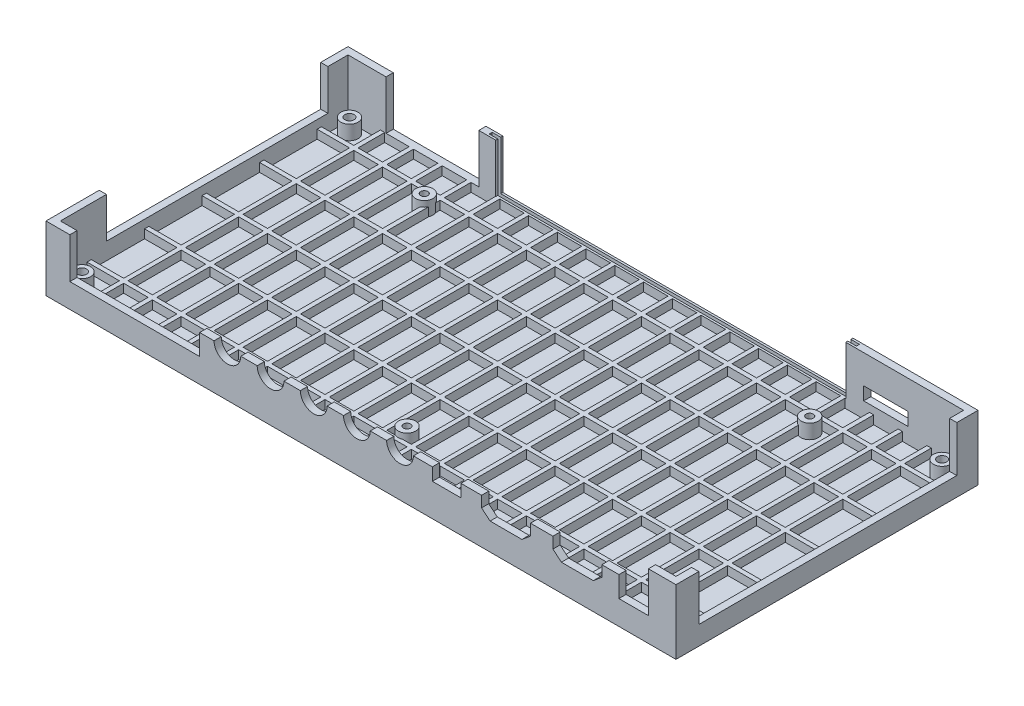
from build123d import *

# Parameters (mm, degrees)
SKETCH1_W                                    = 219
SKETCH1_H                                    = 105
SKETCH1_W_2                                  = 214
SKETCH1_H_2                                  = 100
BOSS_EXTRUDE1_DEPTH                          = 20
SKETCH1_3_W                                  = 219
SKETCH1_3_H                                  = 105
BOSS_EXTRUDE2_DEPTH                          = 2.5
SKETCH3_W                                    = 201.121255631
SKETCH3_H                                    = 14.10529534
CUT_EXTRUDE1_DEPTH                           = 10
SKETCH4_W                                    = 89.704948929
SKETCH4_H                                    = 15.953853078
CUT_EXTRUDE2_DEPTH                           = 10
BOSS_EXTRUDE3_DEPTH                          = 2.5
SKETCH6_W                                    = 92
SKETCH6_H                                    = 17
CUT_EXTRUDE3_DEPTH                           = 10
SKETCH7_W                                    = 77
SKETCH7_H                                    = 14.1
CUT_EXTRUDE4_DEPTH                           = 10
SKETCH8_W                                    = 48.543496453
SKETCH8_H                                    = 17
CUT_EXTRUDE5_DEPTH                           = 4
SKETCH9_W                                    = 15.379744564
SKETCH9_H                                    = 4.533254645
CUT_EXTRUDE6_DEPTH                           = 4
SKETCH10_W                                   = 8.868629792
SKETCH10_H                                   = 12.563679554
CUT_EXTRUDE7_DEPTH                           = 4
BOSS_EXTRUDE4_DEPTH                          = 5
CBORE_FOR_M3_HEX_HEAD_CAP_SCREW1_D           = 3.2
CBORE_FOR_M3_HEX_HEAD_CAP_SCREW1_DEPTH       = 10.1
CBORE_FOR_M3_HEX_HEAD_CAP_SCREW1_CBORE_D     = 5.5
CBORE_FOR_M3_HEX_HEAD_CAP_SCREW1_CBORE_DEPTH = 2.5
CBORE_FOR_M3_HEX_HEAD_CAP_SCREW1_TIP         = 0.96137699
SKETCH17_R                                   = 3
BOSS_EXTRUDE5_DEPTH                          = 5
M3_TAPPED_HOLE1_D                            = 2.5
M3_TAPPED_HOLE1_DEPTH                        = 5
M3_TAPPED_HOLE1_TIP                          = 0.751075774
BOSS_EXTRUDE6_DEPTH                          = 2.5
SKETCH23_W                                   = 20.036006658
SKETCH23_H                                   = 17
CUT_EXTRUDE8_DEPTH                           = 10
SKETCH24_W                                   = 5.878138763
SKETCH24_H                                   = 17
BOSS_EXTRUDE7_DEPTH                          = 2.5
SKETCH25_W                                   = 127.698647885
SKETCH25_H                                   = 1.05
CUT_EXTRUDE9_DEPTH                           = 19
SKETCH26_W                                   = 1.5
SKETCH26_H                                   = 100
BOSS_EXTRUDE8_DEPTH                          = 3
SKETCH27_W                                   = 214
SKETCH27_H                                   = 1.5
BOSS_EXTRUDE9_DEPTH                          = 3


with BuildPart() as part:
    # Sketch1 → Boss-Extrude1 (new body)
    with BuildSketch(Plane(origin=(0, 0, 0), x_dir=(1, 0, 0), z_dir=(0, 1, 0))):
        Rectangle(SKETCH1_W, SKETCH1_H)
        Rectangle(SKETCH1_W_2, SKETCH1_H_2, mode=Mode.SUBTRACT)
    extrude(amount=BOSS_EXTRUDE1_DEPTH)

    # Sketch1_3 → Boss-Extrude2 (add)
    with BuildSketch(Plane(origin=(0, 0, 0), x_dir=(1, 0, 0), z_dir=(0, 1, 0))):
        Rectangle(SKETCH1_3_W, SKETCH1_3_H)
    extrude(amount=-BOSS_EXTRUDE2_DEPTH)

    # Sketch3 → Cut-Extrude1 (cut)
    with BuildSketch(Plane.XY.offset(52.5)):
        with Locations((-0.640205513, 12.94735233)):
            Rectangle(SKETCH3_W, SKETCH3_H)
    extrude(amount=-CUT_EXTRUDE1_DEPTH, mode=Mode.SUBTRACT)

    # Sketch4 → Cut-Extrude2 (cut)
    with BuildSketch(Plane(origin=(109.5, 0, 0), x_dir=(0, 0, -1), z_dir=(1, 0, 0))):
        with Locations((0.276412827, 12.023073461)):
            Rectangle(SKETCH4_W, SKETCH4_H)
    extrude(amount=-CUT_EXTRUDE2_DEPTH, mode=Mode.SUBTRACT)

    # Sketch5 → Boss-Extrude3 (add)
    with BuildSketch(Plane.XY.offset(52.5)):
        with BuildLine():
            Line((-56.08, 5.89470466), (22.72, 5.89470466))
            Line((22.72, 5.89470466), (22.72, 13.13470466))
            Line((22.72, 13.13470466), (18.22, 13.13470466))
            ThreePointArc((18.22, 13.13470466), (13.57, 8.48470466), (8.92, 13.13470466))
            Line((8.92, 13.13470466), (3.22, 13.13470466))
            ThreePointArc((3.22, 13.13470466), (-1.43, 8.48470466), (-6.08, 13.13470466))
            Line((-6.08, 13.13470466), (-11.78, 13.13470466))
            ThreePointArc((-11.78, 13.13470466), (-16.43, 8.48470466), (-21.08, 13.13470466))
            Line((-21.08, 13.13470466), (-26.78, 13.13470466))
            ThreePointArc((-26.78, 13.13470466), (-31.43, 8.48470466), (-36.08, 13.13470466))
            Line((-36.08, 13.13470466), (-41.78, 13.13470466))
            ThreePointArc((-41.78, 13.13470466), (-46.43, 8.48470466), (-51.08, 13.13470466))
            Line((-51.08, 13.13470466), (-56.08, 13.13470466))
            Line((-56.08, 13.13470466), (-56.08, 5.89470466))
        make_face()
    extrude(amount=-BOSS_EXTRUDE3_DEPTH)

    # Sketch6 → Cut-Extrude3 (cut)
    with BuildSketch(Plane(origin=(0, 0, -52.5), x_dir=(-1, 0, 0), z_dir=(0, 0, -1))):
        with Locations((0, 11.5)):
            Rectangle(SKETCH6_W, SKETCH6_H)
    extrude(amount=-CUT_EXTRUDE3_DEPTH, mode=Mode.SUBTRACT)

    # Sketch7 → Cut-Extrude4 (cut)
    with BuildSketch(Plane.ZY.offset(109.5)):
        with Locations((-4.5, 12.95)):
            Rectangle(SKETCH7_W, SKETCH7_H)
    extrude(amount=-CUT_EXTRUDE4_DEPTH, mode=Mode.SUBTRACT)

    # Sketch8 → Cut-Extrude5 (cut)
    with BuildSketch(Plane(origin=(0, 0, -52.5), x_dir=(-1, 0, 0), z_dir=(0, 0, -1))):
        with Locations((69.503394456, 11.5)):
            Rectangle(SKETCH8_W, SKETCH8_H)
    extrude(amount=-CUT_EXTRUDE5_DEPTH, mode=Mode.SUBTRACT)

    # Sketch9 → Cut-Extrude6 (cut)
    with BuildSketch(Plane.XY.offset(-50)):
        with Locations((79.936975281, 7.733372678)):
            Rectangle(SKETCH9_W, SKETCH9_H)
    extrude(amount=-CUT_EXTRUDE6_DEPTH, mode=Mode.SUBTRACT)

    # Sketch10 → Cut-Extrude7 (cut)
    with BuildSketch(Plane.XY.offset(-50)):
        with Locations((59.716857299, 11.778604059)):
            Rectangle(SKETCH10_W, SKETCH10_H)
    extrude(amount=-CUT_EXTRUDE7_DEPTH, mode=Mode.SUBTRACT)

    # Sketch15 → Boss-Extrude4 (add)
    with BuildSketch(Plane(origin=(0, 0, 0), x_dir=(1, 0, 0), z_dir=(0, 1, 0))):
        with BuildLine():
            ThreePointArc((-100, 46.5), (-105.121320344, 48.621320344), (-103, 43.5))
            Line((-103, 43.5), (-103, 46.5))
            Line((-103, 46.5), (-100, 46.5))
        make_face()
        with BuildLine():
            Line((-103, 46.5), (-103, 43.5))
            ThreePointArc((-103, 43.5), (-100.878679656, 44.378679656), (-100, 46.5))
            Line((-100, 46.5), (-103, 46.5))
        make_face()
        with BuildLine():
            Line((-103, -43.5), (-103, -46.5))
            Line((-103, -46.5), (-100, -46.5))
            ThreePointArc((-100, -46.5), (-100.878679656, -44.378679656), (-103, -43.5))
        make_face()
        with BuildLine():
            Line((-100, -46.5), (-103, -46.5))
            Line((-103, -46.5), (-103, -43.5))
            ThreePointArc((-103, -43.5), (-105.121320344, -48.621320344), (-100, -46.5))
        make_face()
        with BuildLine():
            ThreePointArc((103, -43.5), (100.878679656, -44.378679656), (100, -46.5))
            Line((100, -46.5), (103, -46.5))
            Line((103, -46.5), (103, -43.5))
        make_face()
        with BuildLine():
            Line((103, -46.5), (100, -46.5))
            ThreePointArc((100, -46.5), (103, -49.5), (106, -46.5))
            ThreePointArc((106, -46.5), (105.121320344, -44.378679656), (103, -43.5))
            Line((103, -43.5), (103, -46.5))
        make_face()
        with BuildLine():
            ThreePointArc((100, 46.5), (100.878679656, 44.378679656), (103, 43.5))
            Line((103, 43.5), (103, 46.5))
            Line((103, 46.5), (100, 46.5))
        make_face()
        with BuildLine():
            Line((103, 46.5), (103, 43.5))
            ThreePointArc((103, 43.5), (105.121320344, 44.378679656), (106, 46.5))
            ThreePointArc((106, 46.5), (103, 49.5), (100, 46.5))
            Line((100, 46.5), (103, 46.5))
        make_face()
    extrude(amount=BOSS_EXTRUDE4_DEPTH)

    # CBORE for M3 Hex Head Cap Screw1
    with Locations(Plane(origin=(0, -2.5, 0), x_dir=(-1, 0, 0), z_dir=(0, -1, 0))):
        with Locations((103, -46.5), (-103, -46.5), (-103, 46.5), (103, 46.5)):
            CounterBoreHole(CBORE_FOR_M3_HEX_HEAD_CAP_SCREW1_D / 2, CBORE_FOR_M3_HEX_HEAD_CAP_SCREW1_CBORE_D / 2, CBORE_FOR_M3_HEX_HEAD_CAP_SCREW1_CBORE_DEPTH, depth=CBORE_FOR_M3_HEX_HEAD_CAP_SCREW1_DEPTH)
            with Locations((0, 0, -(CBORE_FOR_M3_HEX_HEAD_CAP_SCREW1_DEPTH + CBORE_FOR_M3_HEX_HEAD_CAP_SCREW1_TIP / 2))):  # 118° drill point
                Cone(0, CBORE_FOR_M3_HEX_HEAD_CAP_SCREW1_D / 2, CBORE_FOR_M3_HEX_HEAD_CAP_SCREW1_TIP, mode=Mode.SUBTRACT)

    # Sketch17 → Boss-Extrude5 (add)
    with BuildSketch(Plane(origin=(0, 0, 0), x_dir=(1, 0, 0), z_dir=(0, 1, 0))):
        with Locations((-67, 36.5)):
            Circle(SKETCH17_R)
        with Locations((67, 36.5)):
            Circle(SKETCH17_R)
        with Locations((0, -36.5)):
            Circle(SKETCH17_R)
    extrude(amount=BOSS_EXTRUDE5_DEPTH)

    # M3 Tapped Hole1
    with Locations(Plane(origin=(0, 5, 0), x_dir=(1, 0, 0), z_dir=(0, 1, 0))):
        with Locations((-67, 36.5), (67, 36.5), (0, -36.5)):
            Hole(M3_TAPPED_HOLE1_D / 2, depth=M3_TAPPED_HOLE1_DEPTH)
            with Locations((0, 0, -(M3_TAPPED_HOLE1_DEPTH + M3_TAPPED_HOLE1_TIP / 2))):  # 118° drill point
                Cone(0, M3_TAPPED_HOLE1_D / 2, M3_TAPPED_HOLE1_TIP, mode=Mode.SUBTRACT)

    # Sketch21 → Boss-Extrude6 (add)
    with BuildSketch(Plane.XY.offset(52.5)):
        Polygon((22.72, 13.13470466), (24.800621472, 13.13470466), (24.800621472, 8.766769284), (34.738664035, 8.766769284), (34.738664035, 13.13470466), (41.920422302, 13.13470466), (41.920422302, 9.332760848), (44.883855391, 6.846145236), (55.956989212, 6.846145236), (58.920422302, 9.332760848), (58.920422302, 13.220159757), (66.720422302, 13.220159757), (66.720422302, 9.332760848), (69.683855391, 6.846145236), (80.756989212, 6.846145236), (83.720422302, 9.332760848), (83.720422302, 13.13470466), (89.667078782, 13.13470466), (89.667078782, 5.89470466), (22.72, 5.89470466), align=None)
    extrude(amount=-BOSS_EXTRUDE6_DEPTH)

    # Sketch23 → Cut-Extrude8 (cut)
    with BuildSketch(Plane(origin=(0, 0, -52.5), x_dir=(-1, 0, 0), z_dir=(0, 0, -1))):
        with Locations((-56.018003329, 11.5)):
            Rectangle(SKETCH23_W, SKETCH23_H)
    extrude(amount=-CUT_EXTRUDE8_DEPTH, mode=Mode.SUBTRACT)

    # Sketch24 → Boss-Extrude7 (add)
    with BuildSketch(Plane(origin=(0, 0, -52.5), x_dir=(-1, 0, 0), z_dir=(0, 0, -1))):
        with Locations((58.601710608, 11.5)):
            Rectangle(SKETCH24_W, SKETCH24_H)
    extrude(amount=-BOSS_EXTRUDE7_DEPTH)

    # Sketch25 → Cut-Extrude9 (cut)
    with BuildSketch(Plane(origin=(0, 20, 0), x_dir=(1, 0, 0), z_dir=(0, 1, 0))):
        with Locations((5.186682716, 51.234318365)):
            Rectangle(SKETCH25_W, SKETCH25_H)
    extrude(amount=-CUT_EXTRUDE9_DEPTH, mode=Mode.SUBTRACT)

    # Sketch26 → Boss-Extrude8 (add)
    with BuildSketch(Plane(origin=(0, 0, 0), x_dir=(1, 0, 0), z_dir=(0, 1, 0))):
        with Locations((95, 0)):
            Rectangle(SKETCH26_W, SKETCH26_H)
        with Locations((85, 0)):
            Rectangle(SKETCH26_W, SKETCH26_H)
        with Locations((75, 0)):
            Rectangle(SKETCH26_W, SKETCH26_H)
        with Locations((65, 0)):
            Rectangle(SKETCH26_W, SKETCH26_H)
        with Locations((55, 0)):
            Rectangle(SKETCH26_W, SKETCH26_H)
        with Locations((45, 0)):
            Rectangle(SKETCH26_W, SKETCH26_H)
        with Locations((35, 0)):
            Rectangle(SKETCH26_W, SKETCH26_H)
        with Locations((25, 0)):
            Rectangle(SKETCH26_W, SKETCH26_H)
        with Locations((15, 0)):
            Rectangle(SKETCH26_W, SKETCH26_H)
        with Locations((5, 0)):
            Rectangle(SKETCH26_W, SKETCH26_H)
        with Locations((-5, 0)):
            Rectangle(SKETCH26_W, SKETCH26_H)
        with Locations((-15, 0)):
            Rectangle(SKETCH26_W, SKETCH26_H)
        with Locations((-25, 0)):
            Rectangle(SKETCH26_W, SKETCH26_H)
        with Locations((-35, 0)):
            Rectangle(SKETCH26_W, SKETCH26_H)
        with Locations((-45, 0)):
            Rectangle(SKETCH26_W, SKETCH26_H)
        with Locations((-55, 0)):
            Rectangle(SKETCH26_W, SKETCH26_H)
        with Locations((-65, 0)):
            Rectangle(SKETCH26_W, SKETCH26_H)
        with Locations((-75, 0)):
            Rectangle(SKETCH26_W, SKETCH26_H)
        with Locations((-85, 0)):
            Rectangle(SKETCH26_W, SKETCH26_H)
        with Locations((-95, 0)):
            Rectangle(SKETCH26_W, SKETCH26_H)
    extrude(amount=BOSS_EXTRUDE8_DEPTH)

    # Sketch27 → Boss-Extrude9 (add)
    with BuildSketch(Plane(origin=(0, 0, 0), x_dir=(1, 0, 0), z_dir=(0, 1, 0))):
        with Locations((0, 40)):
            Rectangle(SKETCH27_W, SKETCH27_H)
        with Locations((0, 20)):
            Rectangle(SKETCH27_W, SKETCH27_H)
        Rectangle(SKETCH27_W, SKETCH27_H)
        with Locations((0, -20)):
            Rectangle(SKETCH27_W, SKETCH27_H)
        with Locations((0, -40)):
            Rectangle(SKETCH27_W, SKETCH27_H)
    extrude(amount=BOSS_EXTRUDE9_DEPTH)


solid = part.part
